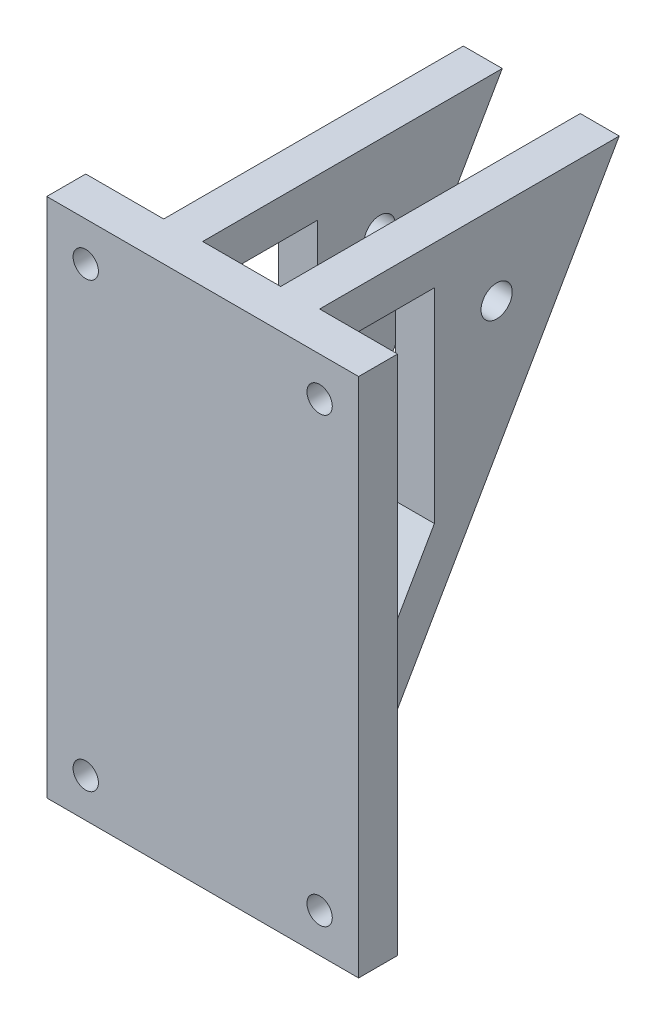
from build123d import *

# Parameters (mm, degrees)
ESBO_O1_R                = 4
RESSALTO_EXTRUS_O2_DEPTH = 10
ESBO_O2_W                = 80
ESBO_O2_H                = 133.630843717
ESBO_O2_R                = 3.25
RESSALTO_EXTRUS_O3_DEPTH = 10


with BuildPart() as part:
    # Esboço1 → Ressalto-extrusão2 (new body)
    with BuildSketch(Plane(origin=(10, 0, 0), x_dir=(0, 0, -1), z_dir=(1, 0, 0))):
        Polygon((0, 0), (76.860522137, 0), (0, -133.630843717), align=None)
        with Locations((45.40940211, -20.909755611)):
            Circle(ESBO_O1_R, mode=Mode.SUBTRACT)
        Polygon((10, -10), (10, -96.187822441), (29.441560186, -62.386437561), (29.441560186, -10), align=None, mode=Mode.SUBTRACT)
    extrude(amount=RESSALTO_EXTRUS_O2_DEPTH)


with BuildPart() as body_2:
    # Espelhar2: mirrored copy
    add(part.part.mirror(Plane(origin=(0, 0, 0), x_dir=(0, 0, 1), z_dir=(1, 0, 0))))


with BuildPart() as part_1:
    add(part.part)

    add(body_2.part)  # Ressalto-extrusão3 merges body 2
    # Esboço2 → Ressalto-extrusão3 (add)
    with BuildSketch(Plane.XY):
        with Locations((0, -66.815421859)):
            Rectangle(ESBO_O2_W, ESBO_O2_H)
        with Locations((-30, -10)):
            Circle(ESBO_O2_R, mode=Mode.SUBTRACT)
        with Locations((30, -10)):
            Circle(ESBO_O2_R, mode=Mode.SUBTRACT)
        with Locations((-30, -123.630843717)):
            Circle(ESBO_O2_R, mode=Mode.SUBTRACT)
        with Locations((30, -123.630843717)):
            Circle(ESBO_O2_R, mode=Mode.SUBTRACT)
    extrude(amount=RESSALTO_EXTRUS_O3_DEPTH)


solid = part_1.part
